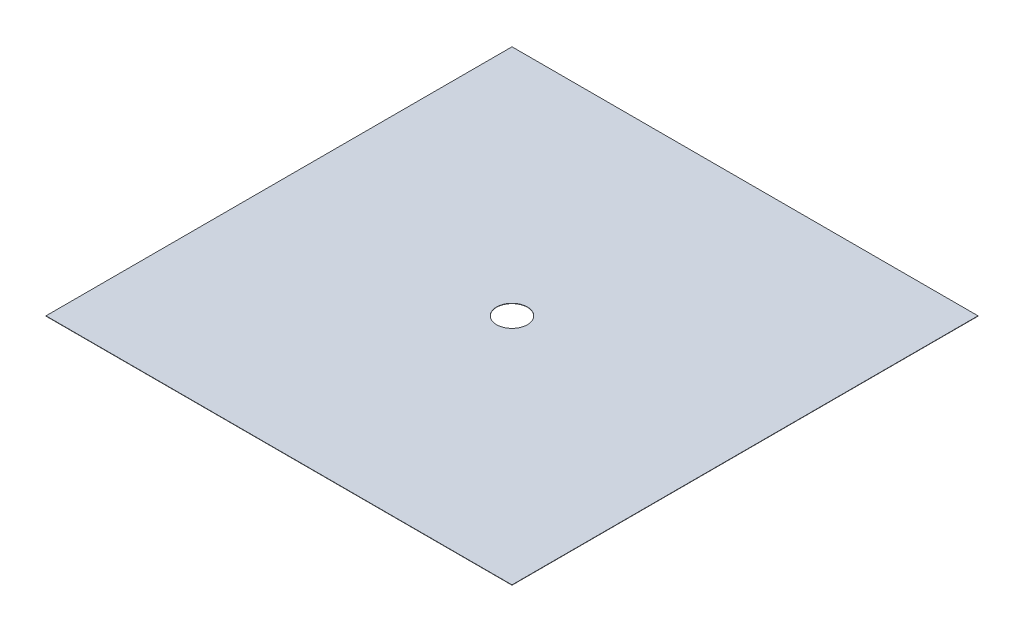
from build123d import *

# Parameters (mm, degrees)
SKETCH1_W           = 530
SKETCH1_H           = 530
SKETCH1_R           = 17.5
BOSS_EXTRUDE1_DEPTH = 0.35


with BuildPart() as part:
    # Sketch1 → Boss-Extrude1 (new body)
    with BuildSketch(Plane(origin=(0, 0, 0), x_dir=(1, 0, 0), z_dir=(0, 1, 0))):
        with Locations((-265, 265)):
            Rectangle(SKETCH1_W, SKETCH1_H)
        with Locations((-265, 265)):
            Circle(SKETCH1_R, mode=Mode.SUBTRACT)
    extrude(amount=BOSS_EXTRUDE1_DEPTH)


solid = part.part
